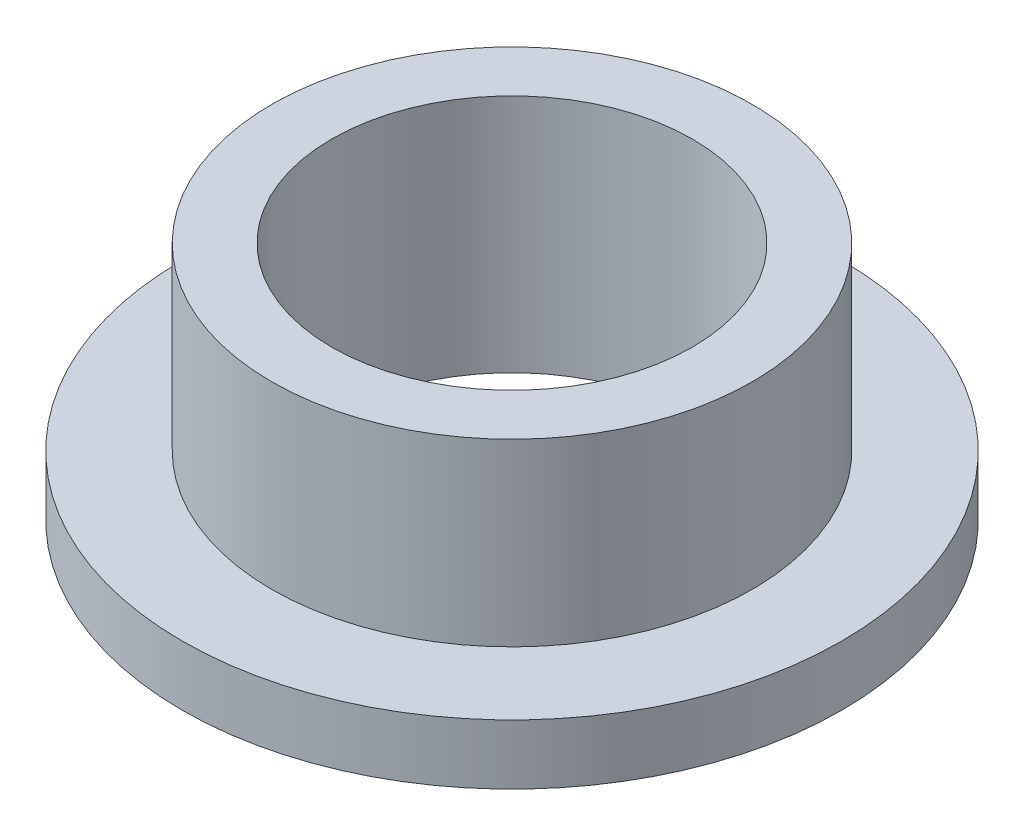
from build123d import *

# Parameters (mm, degrees)
SKETCH2_R           = 6.3627
SKETCH2_R_2         = 4.7752
BOSS_EXTRUDE1_DEPTH = 6.35
SKETCH3_R           = 8.73125
SKETCH3_R_2         = 6.3627
BOSS_EXTRUDE2_DEPTH = 1.5875


with BuildPart() as part:
    # Sketch2 → Boss-Extrude1 (new body)
    with BuildSketch(Plane(origin=(0, 0, 0), x_dir=(1, 0, 0), z_dir=(0, 1, 0))):
        Circle(SKETCH2_R)
        Circle(SKETCH2_R_2, mode=Mode.SUBTRACT)
    extrude(amount=BOSS_EXTRUDE1_DEPTH)

    # Sketch3 → Boss-Extrude2 (add)
    with BuildSketch(Plane(origin=(0, 0, 0), x_dir=(1, 0, 0), z_dir=(0, 1, 0))):
        Circle(SKETCH3_R)
        Circle(SKETCH3_R_2, mode=Mode.SUBTRACT)
    extrude(amount=BOSS_EXTRUDE2_DEPTH)


solid = part.part
